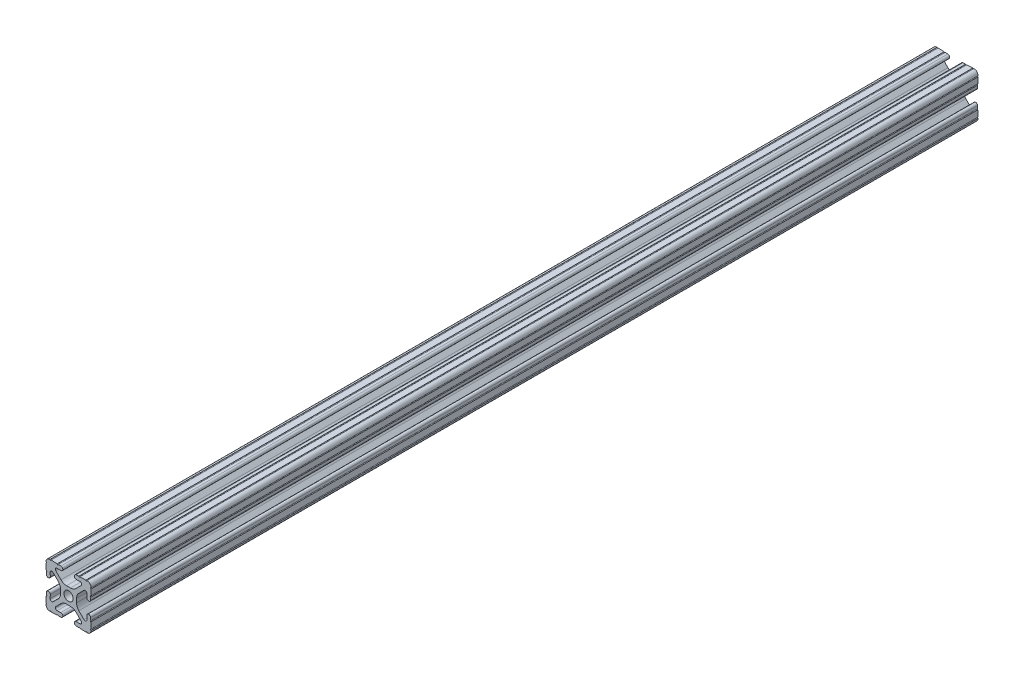
from build123d import *

# Parameters (mm, degrees)
SKETCH3_R               = 2.6035
EXTRUDE1_DEPTH          = 609.6
SKETCH5_W               = 65.927676168
SKETCH5_H               = 719.2
CUT_EXTRUDE1_DEPTH      = 10
CUT_EXTRUDE1_DEPTH_BACK = 34


with BuildPart() as part:
    # Sketch3 → Extrude1 (new body, symmetric)
    with BuildSketch(Plane.XY):
        with BuildLine():
            Line((-1.115277175, 4.5085), (1.115277175, 4.5085))
            ThreePointArc((1.115277175, 4.5085), (2.806584872, 4.844922018), (4.240406305, 5.80297087))
            Line((4.240406305, 5.80297087), (7.148423664, 8.710988229))
            ThreePointArc((7.148423664, 8.710988229), (7.349906316, 9.772227925), (6.436353897, 10.348636575))
            Line((6.436353897, 10.348636575), (4.381960454, 10.276895575))
            ThreePointArc((4.381960454, 10.276895575), (3.239173075, 11.342562046), (4.304839546, 12.485349424))
            Line((4.304839546, 12.485349424), (5.728246175, 12.535055879))
            ThreePointArc((5.728246175, 12.535055879), (6.054756855, 12.230579745), (6.35923299, 12.557090424))
            Line((6.35923299, 12.557090424), (9.782092278, 12.676619304))
            ThreePointArc((9.782092278, 12.676619304), (10.108602958, 12.37214317), (10.413079092, 12.69865385))
            ThreePointArc((10.413079092, 12.69865385), (12.052764565, 12.052764565), (12.69865385, 10.413079092))
            ThreePointArc((12.69865385, 10.413079092), (12.37214317, 10.108602958), (12.676619304, 9.782092278))
            Line((12.676619304, 9.782092278), (12.557090424, 6.35923299))
            ThreePointArc((12.557090424, 6.35923299), (12.230579745, 6.054756855), (12.535055879, 5.728246175))
            Line((12.535055879, 5.728246175), (12.485349424, 4.304839546))
            ThreePointArc((12.485349424, 4.304839546), (11.342562046, 3.239173075), (10.276895575, 4.381960454))
            Line((10.276895575, 4.381960454), (10.348636575, 6.436353897))
            ThreePointArc((10.348636575, 6.436353897), (9.772227925, 7.349906316), (8.710988229, 7.148423664))
            Line((8.710988229, 7.148423664), (5.80297087, 4.240406305))
            ThreePointArc((5.80297087, 4.240406305), (4.844922018, 2.806584872), (4.5085, 1.115277175))
            Line((4.5085, 1.115277175), (4.5085, -1.115277175))
            ThreePointArc((4.5085, -1.115277175), (4.844922018, -2.806584872), (5.80297087, -4.240406305))
            Line((5.80297087, -4.240406305), (8.710988229, -7.148423664))
            ThreePointArc((8.710988229, -7.148423664), (9.772227925, -7.349906316), (10.348636575, -6.436353897))
            Line((10.348636575, -6.436353897), (10.276895575, -4.381960454))
            ThreePointArc((10.276895575, -4.381960454), (11.342562046, -3.239173075), (12.485349424, -4.304839546))
            Line((12.485349424, -4.304839546), (12.535055879, -5.728246175))
            ThreePointArc((12.535055879, -5.728246175), (12.230579745, -6.054756855), (12.557090424, -6.35923299))
            Line((12.557090424, -6.35923299), (12.676619304, -9.782092278))
            ThreePointArc((12.676619304, -9.782092278), (12.37214317, -10.108602958), (12.69865385, -10.413079092))
            ThreePointArc((12.69865385, -10.413079092), (12.052764565, -12.052764565), (10.413079092, -12.69865385))
            ThreePointArc((10.413079092, -12.69865385), (10.108602958, -12.37214317), (9.782092278, -12.676619304))
            Line((9.782092278, -12.676619304), (6.35923299, -12.557090424))
            ThreePointArc((6.35923299, -12.557090424), (6.054756855, -12.230579745), (5.728246175, -12.535055879))
            Line((5.728246175, -12.535055879), (4.304839546, -12.485349424))
            ThreePointArc((4.304839546, -12.485349424), (3.239173075, -11.342562046), (4.381960454, -10.276895575))
            Line((4.381960454, -10.276895575), (6.436353897, -10.348636575))
            ThreePointArc((6.436353897, -10.348636575), (7.349906316, -9.772227925), (7.148423664, -8.710988229))
            Line((7.148423664, -8.710988229), (4.240406305, -5.80297087))
            ThreePointArc((4.240406305, -5.80297087), (2.806584872, -4.844922018), (1.115277175, -4.5085))
            Line((1.115277175, -4.5085), (-1.115277175, -4.5085))
            ThreePointArc((-1.115277175, -4.5085), (-2.806584872, -4.844922018), (-4.240406305, -5.80297087))
            Line((-4.240406305, -5.80297087), (-7.148423664, -8.710988229))
            ThreePointArc((-7.148423664, -8.710988229), (-7.349906316, -9.772227925), (-6.436353897, -10.348636575))
            Line((-6.436353897, -10.348636575), (-4.381960454, -10.276895575))
            ThreePointArc((-4.381960454, -10.276895575), (-3.239173075, -11.342562046), (-4.304839546, -12.485349424))
            Line((-4.304839546, -12.485349424), (-5.728246175, -12.535055879))
            ThreePointArc((-5.728246175, -12.535055879), (-6.054756855, -12.230579745), (-6.35923299, -12.557090424))
            Line((-6.35923299, -12.557090424), (-9.782092278, -12.676619304))
            ThreePointArc((-9.782092278, -12.676619304), (-10.108602958, -12.37214317), (-10.413079092, -12.69865385))
            ThreePointArc((-10.413079092, -12.69865385), (-12.052764565, -12.052764565), (-12.69865385, -10.413079092))
            ThreePointArc((-12.69865385, -10.413079092), (-12.37214317, -10.108602958), (-12.676619304, -9.782092278))
            Line((-12.676619304, -9.782092278), (-12.557090424, -6.35923299))
            ThreePointArc((-12.557090424, -6.35923299), (-12.230579745, -6.054756855), (-12.535055879, -5.728246175))
            Line((-12.535055879, -5.728246175), (-12.485349424, -4.304839546))
            ThreePointArc((-12.485349424, -4.304839546), (-11.342562046, -3.239173075), (-10.276895575, -4.381960454))
            Line((-10.276895575, -4.381960454), (-10.348636575, -6.436353897))
            ThreePointArc((-10.348636575, -6.436353897), (-9.772227925, -7.349906316), (-8.710988229, -7.148423664))
            Line((-8.710988229, -7.148423664), (-5.80297087, -4.240406305))
            ThreePointArc((-5.80297087, -4.240406305), (-4.844922018, -2.806584872), (-4.5085, -1.115277175))
            Line((-4.5085, -1.115277175), (-4.5085, 1.115277175))
            ThreePointArc((-4.5085, 1.115277175), (-4.844922018, 2.806584872), (-5.80297087, 4.240406305))
            Line((-5.80297087, 4.240406305), (-8.710988229, 7.148423664))
            ThreePointArc((-8.710988229, 7.148423664), (-9.772227925, 7.349906316), (-10.348636575, 6.436353897))
            Line((-10.348636575, 6.436353897), (-10.276895575, 4.381960454))
            ThreePointArc((-10.276895575, 4.381960454), (-11.342562046, 3.239173075), (-12.485349424, 4.304839546))
            Line((-12.485349424, 4.304839546), (-12.535055879, 5.728246175))
            ThreePointArc((-12.535055879, 5.728246175), (-12.230579745, 6.054756855), (-12.557090424, 6.35923299))
            Line((-12.557090424, 6.35923299), (-12.676619304, 9.782092278))
            ThreePointArc((-12.676619304, 9.782092278), (-12.37214317, 10.108602958), (-12.69865385, 10.413079092))
            ThreePointArc((-12.69865385, 10.413079092), (-12.052764565, 12.052764565), (-10.413079092, 12.69865385))
            ThreePointArc((-10.413079092, 12.69865385), (-10.108602958, 12.37214317), (-9.782092278, 12.676619304))
            Line((-9.782092278, 12.676619304), (-6.35923299, 12.557090424))
            ThreePointArc((-6.35923299, 12.557090424), (-6.054756855, 12.230579745), (-5.728246175, 12.535055879))
            Line((-5.728246175, 12.535055879), (-4.304839546, 12.485349424))
            ThreePointArc((-4.304839546, 12.485349424), (-3.239173075, 11.342562046), (-4.381960454, 10.276895575))
            Line((-4.381960454, 10.276895575), (-6.436353897, 10.348636575))
            ThreePointArc((-6.436353897, 10.348636575), (-7.349906316, 9.772227925), (-7.148423664, 8.710988229))
            Line((-7.148423664, 8.710988229), (-4.240406305, 5.80297087))
            ThreePointArc((-4.240406305, 5.80297087), (-2.806584872, 4.844922018), (-1.115277175, 4.5085))
        make_face()
        Circle(SKETCH3_R, mode=Mode.SUBTRACT)
    extrude(amount=EXTRUDE1_DEPTH, both=True)

    # Sketch5 → Cut-Extrude1 (cut, two sides)
    with BuildSketch(Plane(origin=(0.430223788, 12.319997369, 0), x_dir=(0.999390827, -0.034899497, 0), z_dir=(0.034899497, 0.999390827, 0))) as cut_extrude1_sk:
        with Locations((-6.086750473, 250)):
            Rectangle(SKETCH5_W, SKETCH5_H)
    extrude(amount=CUT_EXTRUDE1_DEPTH, mode=Mode.SUBTRACT)
    extrude(cut_extrude1_sk.sketch, amount=-CUT_EXTRUDE1_DEPTH_BACK, mode=Mode.SUBTRACT)


solid = part.part
